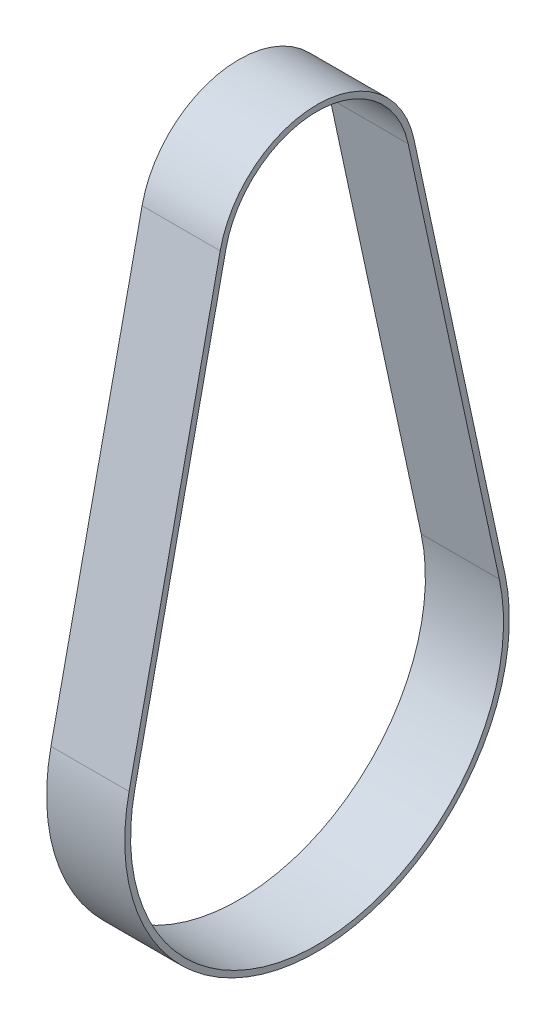
from build123d import *

# Parameters (mm, degrees)
BOSS_EXTRUDE1_DEPTH = 16


with BuildPart() as part:
    # Sketch1 → Boss-Extrude1 (new body)
    with BuildSketch(Plane(origin=(0, 0, 0), x_dir=(0, 0, -1), z_dir=(1, 0, 0))):
        with BuildLine():
            Line((19.842472364, 94.87848019), (38.509948951, 8.30360505))
            ThreePointArc((38.509948951, 8.30360505), (0, -39.395), (-38.509948951, 8.30360505))
            Line((-38.509948951, 8.30360505), (-19.842472364, 94.87848019))
            ThreePointArc((-19.842472364, 94.87848019), (0, 110.8985), (19.842472364, 94.87848019))
        make_face()
        with BuildLine():
            Line((-37.336908241, 8.050671275), (-18.669431655, 94.625546416))
            ThreePointArc((-18.669431655, 94.625546416), (0, 109.6985), (18.669431655, 94.625546416))
            Line((18.669431655, 94.625546416), (37.336908241, 8.050671275))
            ThreePointArc((37.336908241, 8.050671275), (0, -38.195), (-37.336908241, 8.050671275))
        make_face(mode=Mode.SUBTRACT)
    extrude(amount=BOSS_EXTRUDE1_DEPTH)


solid = part.part
